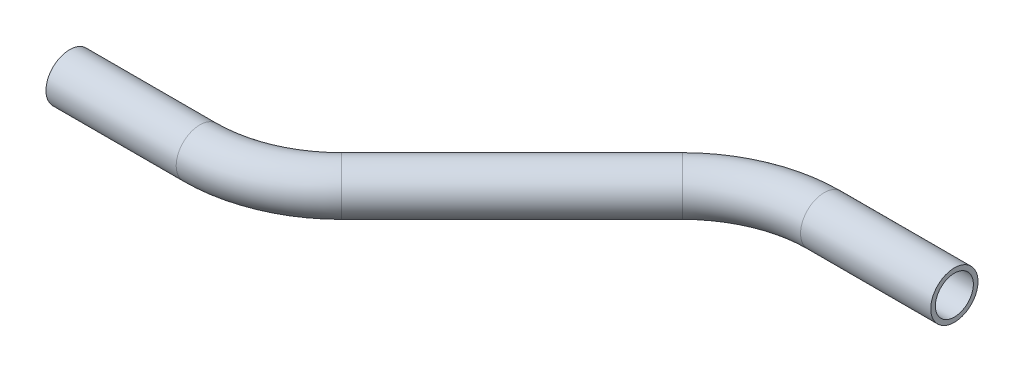
from build123d import *

# Parameters (mm, degrees)
SKETCH2_R   = 6.35
SKETCH2_R_2 = 5.1054


with BuildPart() as part:
    # Sweep1: sweep along a path in Sketch1
    with BuildLine(Plane(origin=(0, 0, 0), x_dir=(1, 0, 0), z_dir=(0, 1, 0))) as sweep1_path:
        Line((0, 0), (35.018463274, 0))
        ThreePointArc((35.018463274, 0), (49.598702047, 2.900189811), (61.959231637, 11.159231637))
        Line((61.959231637, 11.159231637), (107.796909775, 56.996909775))
        ThreePointArc((107.796909775, 56.996909775), (120.157439365, 65.2559516), (134.737678138, 68.156141412))
        Line((134.737678138, 68.156141412), (169.756141412, 68.156141412))
    # Sketch2 → Sweep1 (sweep)
    with BuildSketch(Plane(origin=(0, 0, 0), x_dir=(0, 0, -1), z_dir=(1, 0, 0))):
        Circle(SKETCH2_R)
        Circle(SKETCH2_R_2, mode=Mode.SUBTRACT)
    sweep(path=sweep1_path.line)


solid = part.part
